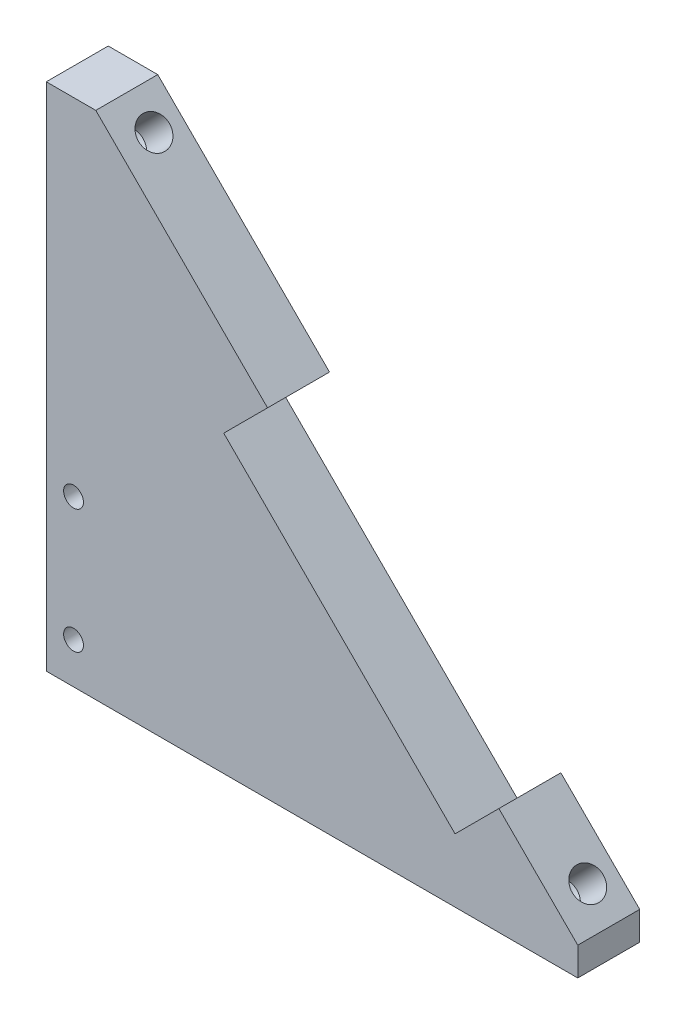
from build123d import *

# Parameters (mm, degrees)
BOSS_EXTRUDE1_DEPTH       = 5
M3X0_5_TAPPED_HOLE1_D     = 2.5
M3X0_5_TAPPED_HOLE1_DEPTH = 3
M3X0_5_TAPPED_HOLE1_TIP   = 0.751075774
BOSS_EXTRUDE2_DEPTH       = 5
CUT_EXTRUDE1_DEPTH        = 6
CUT_EXTRUDE2_DEPTH        = 6
BOSS_EXTRUDE3_DEPTH       = 5
BOSS_EXTRUDE4_DEPTH       = 5
SKETCH15_W                = 42.426406872
SKETCH15_H                = 0.46
BOSS_EXTRUDE6_DEPTH       = 5
SKETCH16_W                = 0.46
SKETCH16_H                = 42.886406871
BOSS_EXTRUDE7_DEPTH       = 5
M2X0_4_TAPPED_HOLE1_D     = 1.6
M2X0_4_TAPPED_HOLE1_DEPTH = 6
M2X0_4_TAPPED_HOLE1_TIP   = 0.480688495
SKETCH21_W                = 42.886406872
SKETCH21_H                = 1.7
CUT_EXTRUDE3_DEPTH        = 6
M3X0_5_TAPPED_HOLE3_D     = 2.5
M3X0_5_TAPPED_HOLE3_DEPTH = 6
M3X0_5_TAPPED_HOLE3_TIP   = 0.751075774


with BuildPart() as part:
    # Sketch2 → Boss-Extrude1 (new body)
    with BuildSketch(Plane.XY):
        Polygon((-19.445436483, 19.445436483), (26.516504294, -26.516504294), (-19.445436483, -26.516504294), align=None)
    extrude(amount=BOSS_EXTRUDE1_DEPTH)

    # M3x0.5 Tapped Hole1
    with Locations(Plane(origin=(0, 0, 0), x_dir=(0, 0, -1), z_dir=(0.707106781, 0.707106781, 0))):
        with Locations((-2.25, 19.75), (-2.25, -29.75)):
            Hole(M3X0_5_TAPPED_HOLE1_D / 2, depth=M3X0_5_TAPPED_HOLE1_DEPTH)
            with Locations((0, 0, -(M3X0_5_TAPPED_HOLE1_DEPTH + M3X0_5_TAPPED_HOLE1_TIP / 2))):  # 118° drill point
                Cone(0, M3X0_5_TAPPED_HOLE1_D / 2, M3X0_5_TAPPED_HOLE1_TIP, mode=Mode.SUBTRACT)

    # Sketch6 → Boss-Extrude2 (add, through all)
    with BuildSketch(Plane.XY.offset(5)):
        Polygon((-19.445436483, 19.445436483), (-15.909902577, 15.909902577), (-14.495689014, 17.324116139), (-18.03122292, 20.859650045), align=None)
        Polygon((26.516504294, -26.516504294), (22.980970389, -22.980970389), (24.395183951, -21.566756826), (27.930717857, -25.102290732), align=None)
    extrude(amount=-BOSS_EXTRUDE2_DEPTH)

    # Sketch7 → Cut-Extrude1 (cut, through all)
    with BuildSketch(Plane.XY.offset(5)):
        Polygon((-2.050609665, 2.050609665), (-5.586143571, -1.48492424), (13.081475452, -20.152543264), (16.617009358, -16.617009358), align=None)
    extrude(amount=-CUT_EXTRUDE1_DEPTH, mode=Mode.SUBTRACT)

    # Sketch9 → Cut-Extrude2 (cut, through all)
    with BuildSketch(Plane.XY.offset(5)):
        Polygon((-15.909902577, 15.909902577), (-19.445436483, 12.374368671), (-19.445436483, 19.445436483), (-18.03122292, 20.859650045), (-14.495689014, 17.324116139), align=None)
        Polygon((27.930717857, -25.102290732), (24.395183951, -21.566756826), (19.445436483, -26.516504294), (26.516504294, -26.516504294), align=None)
    extrude(amount=-CUT_EXTRUDE2_DEPTH, mode=Mode.SUBTRACT)

    # Sketch13 → Boss-Extrude3 (add, through all)
    with BuildSketch(Plane.XY.offset(5)):
        Polygon((22.980970389, -22.980970389), (19.445436483, -26.516504294), (22.980970389, -26.516504294), align=None)
    extrude(amount=-BOSS_EXTRUDE3_DEPTH)

    # Sketch14 → Boss-Extrude4 (add, through all)
    with BuildSketch(Plane.XY.offset(5)):
        Polygon((-19.445436483, 12.374368671), (-19.445436483, 15.909902577), (-15.909902577, 15.909902577), align=None)
    extrude(amount=-BOSS_EXTRUDE4_DEPTH)

    # Sketch15 → Boss-Extrude6 (add, through all)
    with BuildSketch(Plane(origin=(0, 0, 0), x_dir=(-1, 0, 0), z_dir=(0, 0, -1))):
        with Locations((-1.767766953, -26.746504294)):
            Rectangle(SKETCH15_W, SKETCH15_H)
    extrude(amount=-BOSS_EXTRUDE6_DEPTH)

    # Sketch16 → Boss-Extrude7 (add, through all)
    with BuildSketch(Plane(origin=(0, 0, 0), x_dir=(-1, 0, 0), z_dir=(0, 0, -1))):
        with Locations((19.675436483, -5.533300859)):
            Rectangle(SKETCH16_W, SKETCH16_H)
    extrude(amount=-BOSS_EXTRUDE7_DEPTH)

    # M2x0.4 Tapped Hole1
    with Locations(Plane(origin=(0, 0, 0), x_dir=(-1, 0, 0), z_dir=(0, 0, -1))):
        with Locations((17.70619852, -11.976504294), (17.70619852, -21.976504294)):
            Hole(M2X0_4_TAPPED_HOLE1_D / 2, depth=M2X0_4_TAPPED_HOLE1_DEPTH)
            with Locations((0, 0, -(M2X0_4_TAPPED_HOLE1_DEPTH + M2X0_4_TAPPED_HOLE1_TIP / 2))):  # 118° drill point
                Cone(0, M2X0_4_TAPPED_HOLE1_D / 2, M2X0_4_TAPPED_HOLE1_TIP, mode=Mode.SUBTRACT)

    # Sketch21 → Cut-Extrude3 (cut, through all)
    with BuildSketch(Plane.XY.offset(5)):
        with Locations((1.537766953, -26.126504294)):
            Rectangle(SKETCH21_W, SKETCH21_H)
    extrude(amount=-CUT_EXTRUDE3_DEPTH, mode=Mode.SUBTRACT)

    # M3x0.5 Tapped Hole3
    with Locations(Plane(origin=(0, -25.276504294, 0), x_dir=(-1, 0, 0), z_dir=(0, -1, 0))):
        with Locations((7.905436483, -2.5), (-7.094563517, -2.5)):
            Hole(M3X0_5_TAPPED_HOLE3_D / 2, depth=M3X0_5_TAPPED_HOLE3_DEPTH)
            with Locations((0, 0, -(M3X0_5_TAPPED_HOLE3_DEPTH + M3X0_5_TAPPED_HOLE3_TIP / 2))):  # 118° drill point
                Cone(0, M3X0_5_TAPPED_HOLE3_D / 2, M3X0_5_TAPPED_HOLE3_TIP, mode=Mode.SUBTRACT)


solid = part.part
